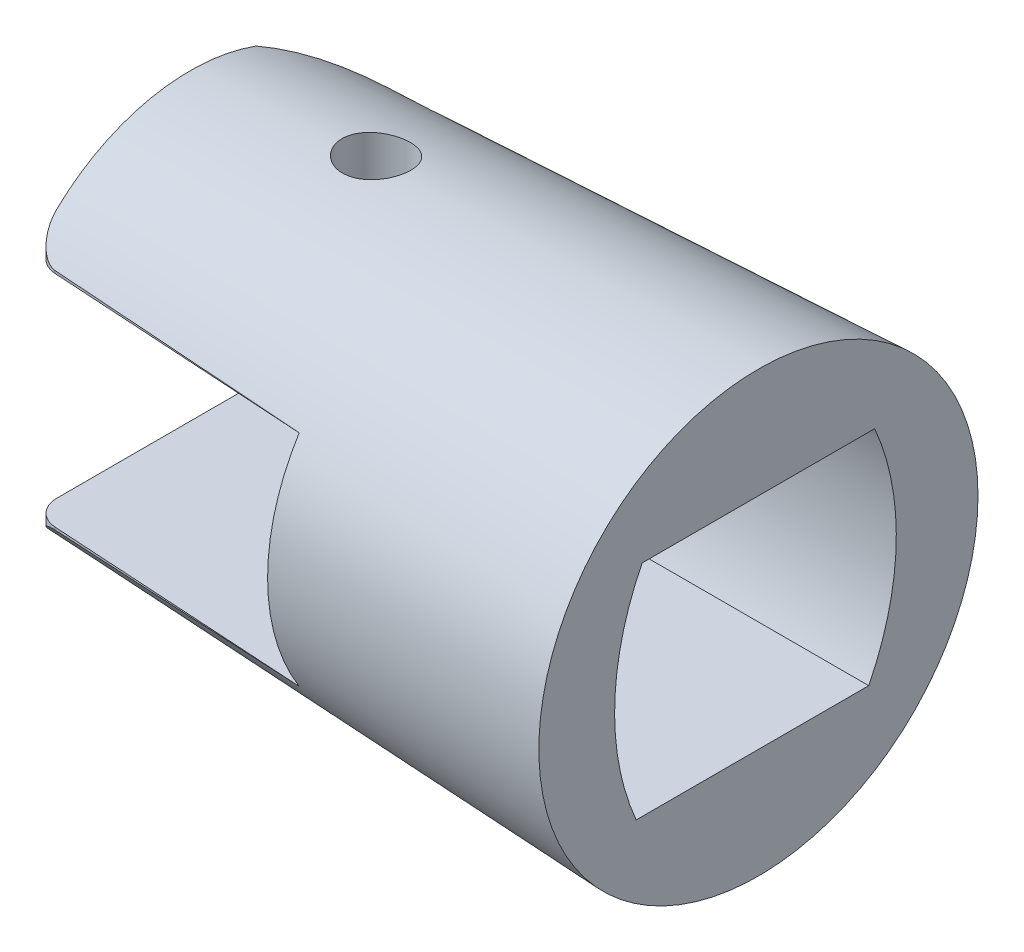
from build123d import *

# Parameters (mm, degrees)
SKETCH3_R          = 8.5
SKETCH2_R          = 7.5
SKETCH4_W          = 13.98
SKETCH4_H          = 8.5
CUT_EXTRUDE1_DEPTH = 10
CUT_EXTRUDE2_DEPTH = 10
SKETCH6_R          = 1.25
CUT_EXTRUDE3_DEPTH = 10
CUT_EXTRUDE4_DEPTH = 12
FILLET1_R          = 1


with BuildPart() as part:
    # Sketch3 → Loft1 section 0
    with BuildSketch(Plane(origin=(0, 0, 0), x_dir=(0, 0, -1), z_dir=(1, 0, 0))):
        Circle(SKETCH3_R)
    # Sketch2 → Loft1 section 1
    with BuildSketch(Plane(origin=(-22, 0, 0), x_dir=(0, 0, -1), z_dir=(1, 0, 0))):
        Circle(SKETCH2_R)
    loft()

    # Sketch4 → Cut-Extrude1 (cut, symmetric)
    with BuildSketch(Plane.XY):
        with Locations((-17.99, 0)):
            Rectangle(SKETCH4_W, SKETCH4_H)
    extrude(amount=CUT_EXTRUDE1_DEPTH, both=True, mode=Mode.SUBTRACT)

    # Sketch5 → Cut-Extrude2 (cut, symmetric)
    with BuildSketch(Plane(origin=(0, 0, 0), x_dir=(1, 0, 0), z_dir=(0, 1, 0))):
        with BuildLine():
            Line((-23, -6.043769414), (-23.024844237, -1.493837243))
            ThreePointArc((-23.024844237, -1.493837243), (-21.216174997, 3.738120473), (-16.53, 6.685056145))
            Line((-16.53, 6.685056145), (-11, 6.777720856))
            Line((-11, 6.777720856), (-11, 10.146746938))
            Line((-11, 10.146746938), (-27.92, 10.146746938))
            Line((-27.92, 10.146746938), (-27.92, -8.723253062))
            Line((-27.92, -8.723253062), (-11, -8.723253062))
            Line((-11, -8.723253062), (-11, -6.777720856))
            Line((-11, -6.777720856), (-23, -6.043769414))
        make_face()
    extrude(amount=CUT_EXTRUDE2_DEPTH, both=True, mode=Mode.SUBTRACT)

    # Sketch6 → Cut-Extrude3 (cut, symmetric)
    with BuildSketch(Plane(origin=(0, 0, 0), x_dir=(1, 0, 0), z_dir=(0, 1, 0))):
        with Locations((-15.3, 0.5)):
            Circle(SKETCH6_R)
    extrude(amount=CUT_EXTRUDE3_DEPTH, both=True, mode=Mode.SUBTRACT)

    # Sketch8 → Cut-Extrude4 (cut)
    with BuildSketch(Plane(origin=(0, 0, 0), x_dir=(0, 0, -1), z_dir=(1, 0, 0))):
        with BuildLine():
            Line((-4.5, 4.25), (4.5, 4.25))
            ThreePointArc((4.5, 4.25), (5.333449887, -0.025663938), (4.27, -4.25))
            Line((4.27, -4.25), (-4.73, -4.25))
            ThreePointArc((-4.73, -4.25), (-5.563449887, 0.025663938), (-4.5, 4.25))
        make_face()
    extrude(amount=-CUT_EXTRUDE4_DEPTH, mode=Mode.SUBTRACT)

    # Fillet1
    fillet1_edges = [part.edges().sort_by_distance(p)[0] for p in [
        (-22, -4.303290893, 6.104932034),
        (-22, 4.303290893, 6.104932034),
    ]]
    fillet(fillet1_edges, radius=FILLET1_R)


solid = part.part
